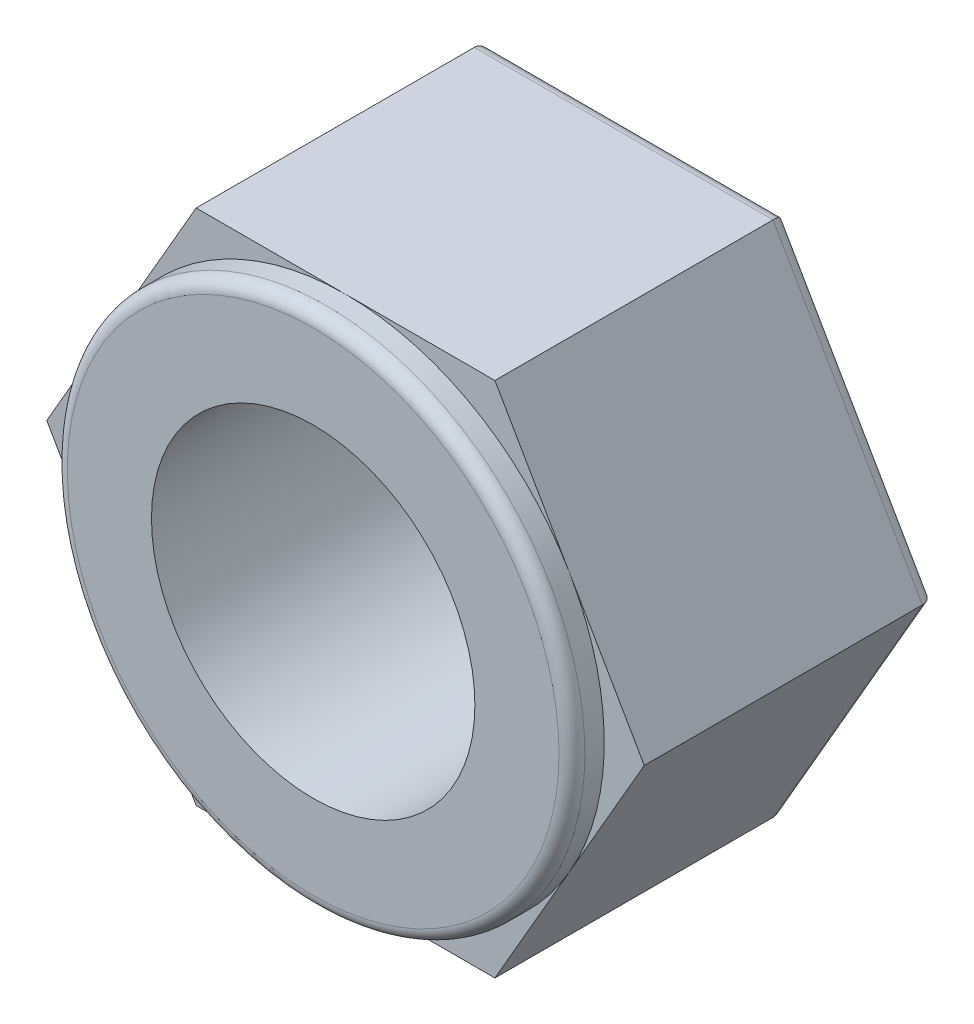
from build123d import *

# Parameters (mm, degrees)
SKETCH_1_R      = 2.5
EXTRUDE_1_DEPTH = 4.5
SKETCH_2_R      = 4
SKETCH_2_R_2    = 2.5
EXTRUDE_2_DEPTH = 0.5
FILLET_1_R      = 0.2
FILLET_2_R      = 0.2


with BuildPart() as part:
    # 草图1 → 凸台-拉伸1 (new body)
    with BuildSketch(Plane.XY):
        Polygon((4.618802154, 0), (2.309401077, 4), (-2.309401077, 4), (-4.618802154, 0), (-2.309401077, -4), (2.309401077, -4), align=None)
        Circle(SKETCH_1_R, mode=Mode.SUBTRACT)
    extrude(amount=EXTRUDE_1_DEPTH)

    # 草图2 → 凸台-拉伸2 (add)
    with BuildSketch(Plane.XY.offset(4.5)):
        Circle(SKETCH_2_R)
        Circle(SKETCH_2_R_2, mode=Mode.SUBTRACT)
    extrude(amount=EXTRUDE_2_DEPTH)

    # 圆角1
    fillet_1_edges = [part.edges().sort_by_distance(p)[0] for p in [
        (-4, 0, 5),
    ]]
    fillet(fillet_1_edges, radius=FILLET_1_R)

    # 圆角2
    fillet_2_edges = [part.edges().sort_by_distance(p)[0] for p in [
        (0, -4, 0),
        (-3.464101615, -2, 0),
        (-3.464101615, 2, 0),
        (0, 4, 0),
        (3.464101615, 2, 0),
        (3.464101615, -2, 0),
    ]]
    fillet(fillet_2_edges, radius=FILLET_2_R)


solid = part.part
